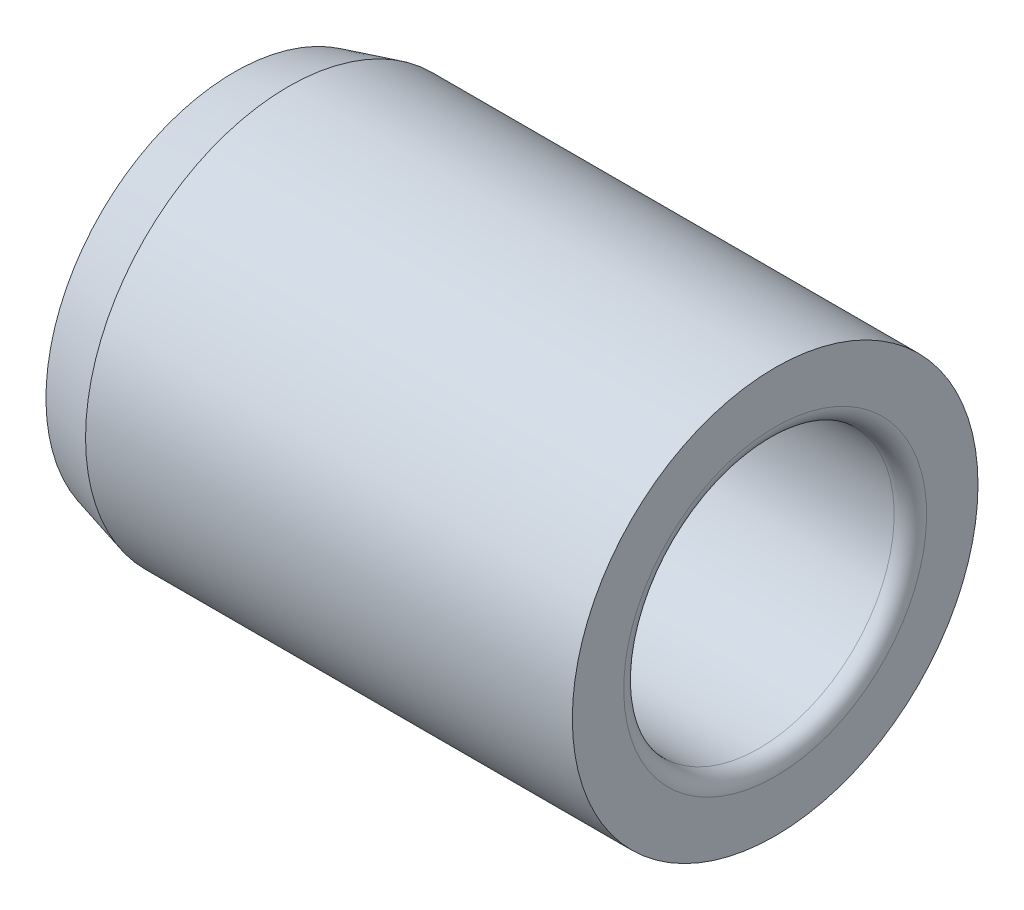
from build123d import *


with BuildPart() as part:
    # Sketch1 → Revolve1 (revolve)
    with BuildSketch(Plane.XY):
        with BuildLine():
            Line((-12.7, 8.844409051), (-10.16, 9.525))
            Line((-10.16, 9.525), (12.7, 9.525))
            Line((12.7, 9.525), (12.7, 7.112))
            ThreePointArc((12.7, 7.112), (12.476815367, 6.573184633), (11.938, 6.35))
            Line((11.938, 6.35), (-12.7, 6.35))
            Line((-12.7, 6.35), (-12.7, 8.844409051))
        make_face()
    revolve(axis=Axis((-12.7, 0, 0), (1, 0, 0)))


solid = part.part
